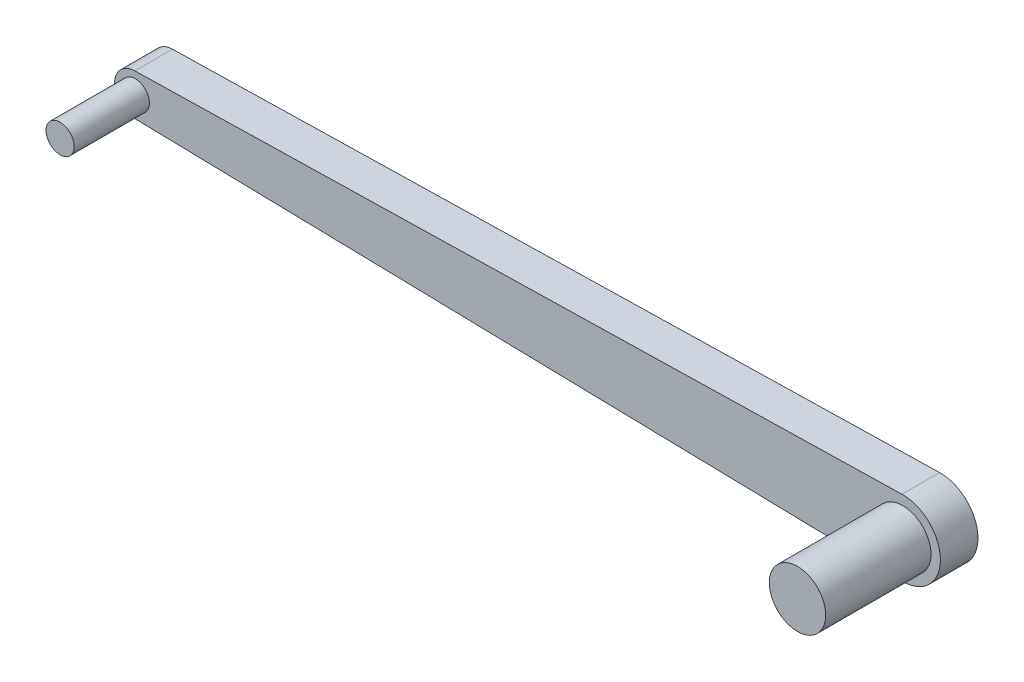
from build123d import *

# Parameters (mm, degrees)
SKETCH1_R           = 0.375
SKETCH1_R_2         = 0.75
BOSS_EXTRUDE1_DEPTH = 0.5
SKETCH1_2_R         = 0.375
BOSS_EXTRUDE2_DEPTH = 2.5
SKETCH1_3_R         = 0.75
BOSS_EXTRUDE3_DEPTH = 3.3
SKETCH2_R           = 0.375
SKETCH2_R_2         = 0.75
BOSS_EXTRUDE4_DEPTH = 0.5


with BuildPart() as part:
    # Sketch1 → Boss-Extrude1 (new body, symmetric)
    with BuildSketch(Plane.XY):
        with BuildLine():
            Line((-10.217126409, 0.549866302), (10.182951984, 0.999756913))
            ThreePointArc((10.182951984, 0.999756913), (11.205, 0), (10.182951984, -0.999756913))
            Line((10.182951984, -0.999756913), (-10.217126409, -0.549866302))
            ThreePointArc((-10.217126409, -0.549866302), (-10.755, 0), (-10.217126409, 0.549866302))
        make_face()
        with Locations((-10.205, 0)):
            Circle(SKETCH1_R, mode=Mode.SUBTRACT)
        with Locations((10.205, 0)):
            Circle(SKETCH1_R_2, mode=Mode.SUBTRACT)
    extrude(amount=BOSS_EXTRUDE1_DEPTH, both=True)

    # Sketch1_2 → Boss-Extrude2 (add)
    with BuildSketch(Plane.XY):
        with Locations((-10.205, 0)):
            Circle(SKETCH1_2_R)
    extrude(amount=BOSS_EXTRUDE2_DEPTH)

    # Sketch1_3 → Boss-Extrude3 (add)
    with BuildSketch(Plane.XY):
        with Locations((10.205, 0)):
            Circle(SKETCH1_3_R)
    extrude(amount=BOSS_EXTRUDE3_DEPTH)

    # Sketch2 → Boss-Extrude4 (add)
    with BuildSketch(Plane(origin=(0, 0, 0), x_dir=(-1, 0, 0), z_dir=(0, 0, -1))):
        with Locations((10.205, 0)):
            Circle(SKETCH2_R)
        with Locations((-10.205, 0)):
            Circle(SKETCH2_R_2)
    extrude(amount=BOSS_EXTRUDE4_DEPTH)


solid = part.part
